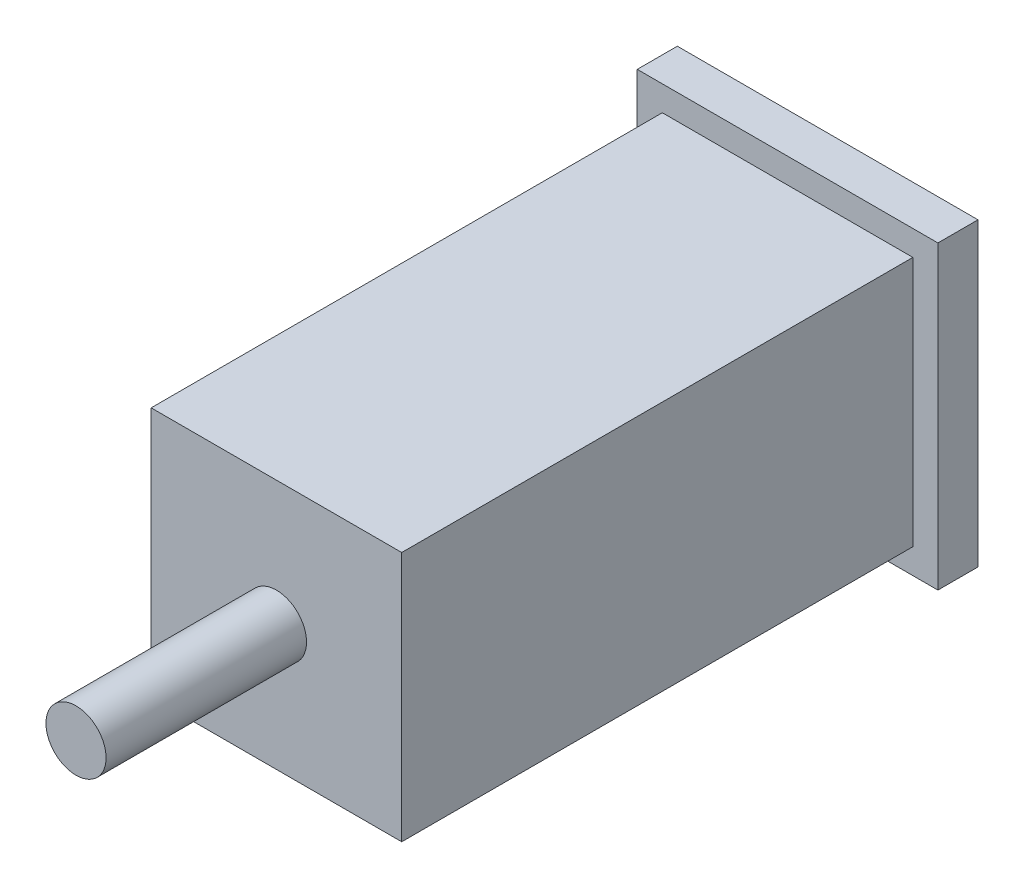
from build123d import *

# Parameters (mm, degrees)
SKETCH1_W           = 30
SKETCH1_H           = 30
BOSS_EXTRUDE1_DEPTH = 4
SKETCH2_W           = 25
SKETCH2_H           = 25
BOSS_EXTRUDE2_DEPTH = 51
SKETCH3_R           = 3
BOSS_EXTRUDE3_DEPTH = 20


with BuildPart() as part:
    # Sketch1 → Boss-Extrude1 (new body)
    with BuildSketch(Plane.XY):
        Rectangle(SKETCH1_W, SKETCH1_H)
    extrude(amount=BOSS_EXTRUDE1_DEPTH)

    # Sketch2 → Boss-Extrude2 (add)
    with BuildSketch(Plane.XY.offset(4)):
        Rectangle(SKETCH2_W, SKETCH2_H)
    extrude(amount=BOSS_EXTRUDE2_DEPTH)

    # Sketch3 → Boss-Extrude3 (add)
    with BuildSketch(Plane.XY.offset(55)):
        Circle(SKETCH3_R)
    extrude(amount=BOSS_EXTRUDE3_DEPTH)


solid = part.part
